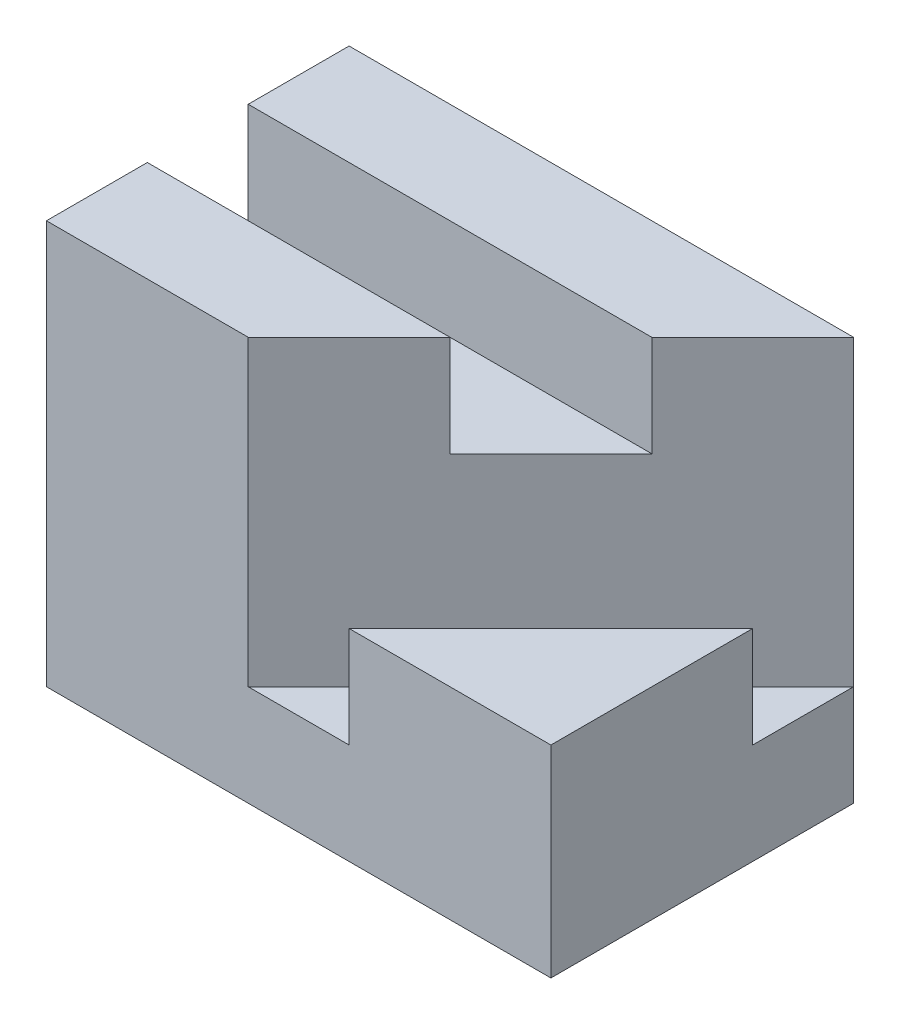
from build123d import *

# Parameters (mm, degrees)
SKETCH_1_W          = 50
SKETCH_1_H          = 30
EXTRUDE_1_DEPTH     = 40
SKETCH_2_W          = 10
SKETCH_2_H          = 10
CUT_EXTRUDE_1_DEPTH = 51
CUT_EXTRUDE_2_DEPTH = 20
CUT_EXTRUDE_3_DEPTH = 30


with BuildPart() as part:
    # 草圖1 → 填料-伸長1 (new body)
    with BuildSketch(Plane(origin=(0, 0, 0), x_dir=(1, 0, 0), z_dir=(0, 1, 0))):
        Rectangle(SKETCH_1_W, SKETCH_1_H)
    extrude(amount=EXTRUDE_1_DEPTH)

    # 草圖2 → 除料-伸長1 (cut, through all)
    with BuildSketch(Plane(origin=(25, 0, 0), x_dir=(0, 0, -1), z_dir=(1, 0, 0))):
        with Locations((0, 35)):
            Rectangle(SKETCH_2_W, SKETCH_2_H)
    extrude(amount=-CUT_EXTRUDE_1_DEPTH, mode=Mode.SUBTRACT)

    # 草圖3 → 除料-伸長2 (cut)
    with BuildSketch(Plane(origin=(0, 40, 0), x_dir=(1, 0, 0), z_dir=(0, 1, 0))):
        Polygon((25, -15), (25, 5), (5, -15), align=None)
    extrude(amount=-CUT_EXTRUDE_2_DEPTH, mode=Mode.SUBTRACT)

    # 草圖4 → 除料-伸長3 (cut)
    with BuildSketch(Plane(origin=(0, 40, 0), x_dir=(1, 0, 0), z_dir=(0, 1, 0))):
        Polygon((25, 15), (-5, -15), (5, -15), (25, 5), align=None)
    extrude(amount=-CUT_EXTRUDE_3_DEPTH, mode=Mode.SUBTRACT)


solid = part.part
